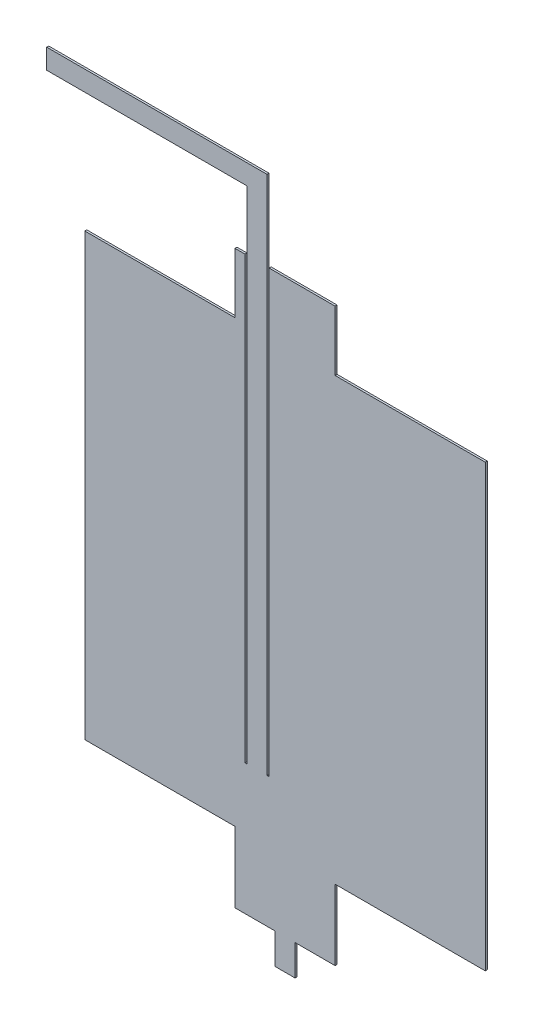
from build123d import *

# Parameters (mm, degrees)
BOSS_EXTRUDE1_DEPTH = 1


with BuildPart() as part:
    # Sketch2 → Boss-Extrude1 (new body)
    with BuildSketch(Plane.XY):
        Polygon((75, -55.232991536), (95, -55.232991536), (95, -70.577436959), (105, -70.577436959), (105, -55.232991536), (125, -55.232991536), (125, -20), (200, -20), (200, 0), (200, 200), (125, 200), (125, 230), (92, 230), (92, 10), (91, 10), (91, 230), (91, 270), (-19, 270), (-19, 260), (81, 260), (81, 230), (81, 10), (80, 10), (80, 230), (75, 230), (75, 200), (0, 200), (0, 0), (0, -20), (75, -20), align=None)
    extrude(amount=BOSS_EXTRUDE1_DEPTH)


solid = part.part
